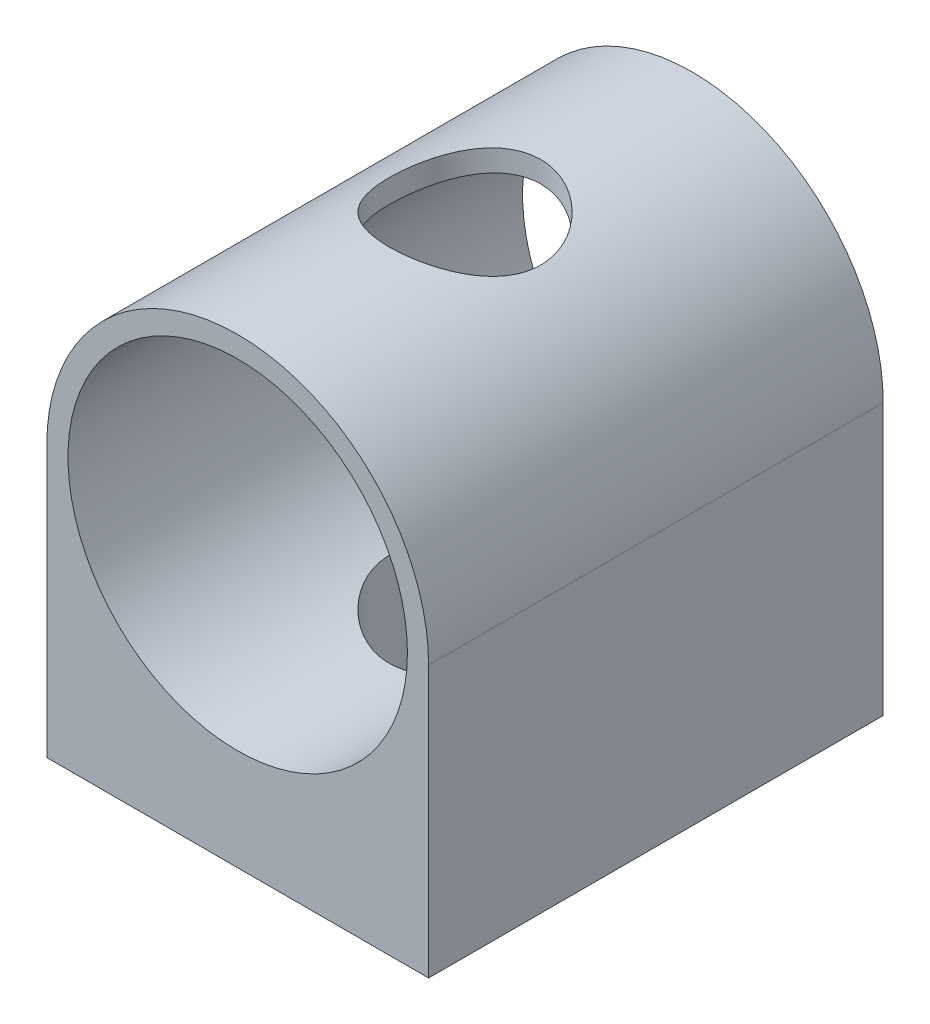
from build123d import *

# Parameters (mm, degrees)
SKETCH1_R           = 14.224
BOSS_EXTRUDE1_DEPTH = 38.1
SKETCH2_R           = 6.35
CUT_EXTRUDE1_DEPTH  = 39.7096


with BuildPart() as part:
    # Sketch1 → Boss-Extrude1 (new body)
    with BuildSketch(Plane.XY):
        with BuildLine():
            Line((16, 0), (-16, 0))
            Line((-16, 0), (-16, 22.7096))
            ThreePointArc((-16, 22.7096), (0, 38.7096), (16, 22.7096))
            Line((16, 22.7096), (16, 0))
        make_face()
        with Locations((0, 22.7096)):
            Circle(SKETCH1_R, mode=Mode.SUBTRACT)
    extrude(amount=BOSS_EXTRUDE1_DEPTH)

    # Sketch2 → Cut-Extrude1 (cut, through all)
    with BuildSketch(Plane.XZ):
        with Locations((0, 19.05)):
            Circle(SKETCH2_R)
    extrude(amount=-CUT_EXTRUDE1_DEPTH, mode=Mode.SUBTRACT)


solid = part.part
